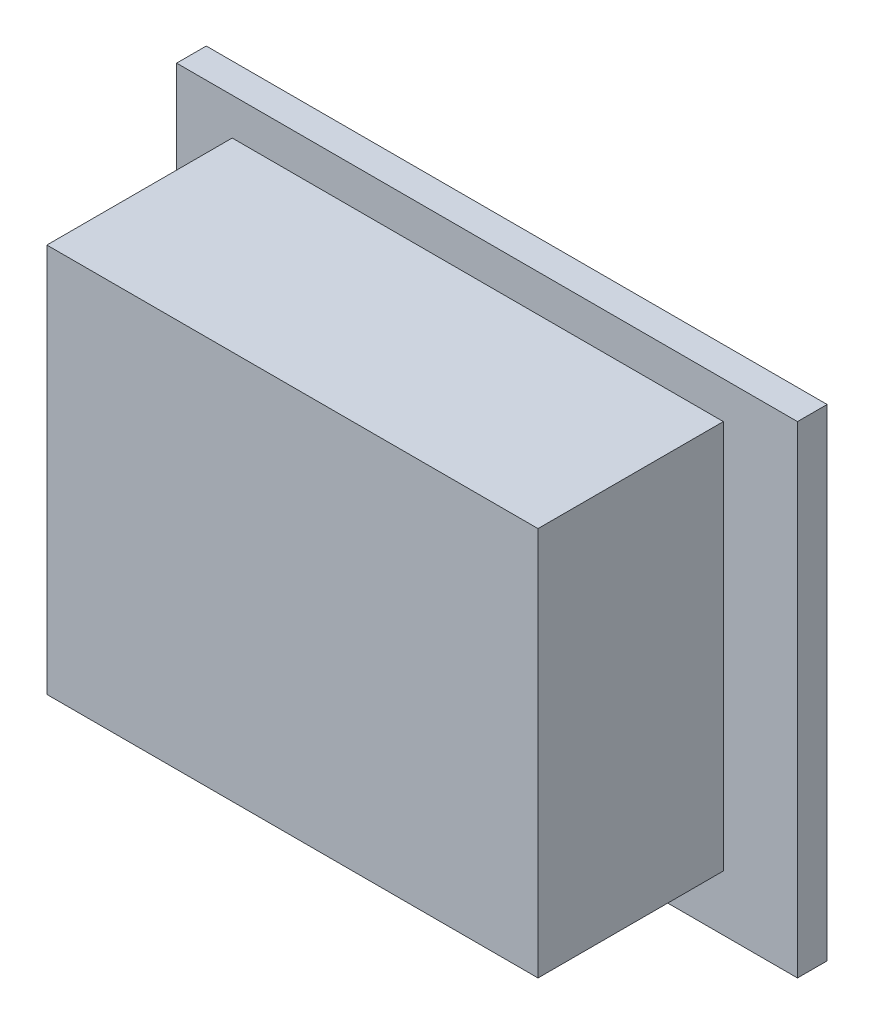
from build123d import *

# Parameters (mm, degrees)
ESQUISSE1_W        = 33.5
ESQUISSE1_H        = 26
BOSS_EXTRU_1_DEPTH = 1.6
ESQUISSE2_W        = 26.5
ESQUISSE2_H        = 21
BOSS_EXTRU_2_DEPTH = 10


with BuildPart() as part:
    # Esquisse1 → Boss.-Extru.1 (new body)
    with BuildSketch(Plane.XY):
        with Locations((16.75, 13)):
            Rectangle(ESQUISSE1_W, ESQUISSE1_H)
    extrude(amount=BOSS_EXTRU_1_DEPTH)

    # Esquisse2 → Boss.-Extru.2 (add)
    with BuildSketch(Plane.XY.offset(1.6)):
        with Locations((16.25, 13.5)):
            Rectangle(ESQUISSE2_W, ESQUISSE2_H)
    extrude(amount=BOSS_EXTRU_2_DEPTH)


solid = part.part
